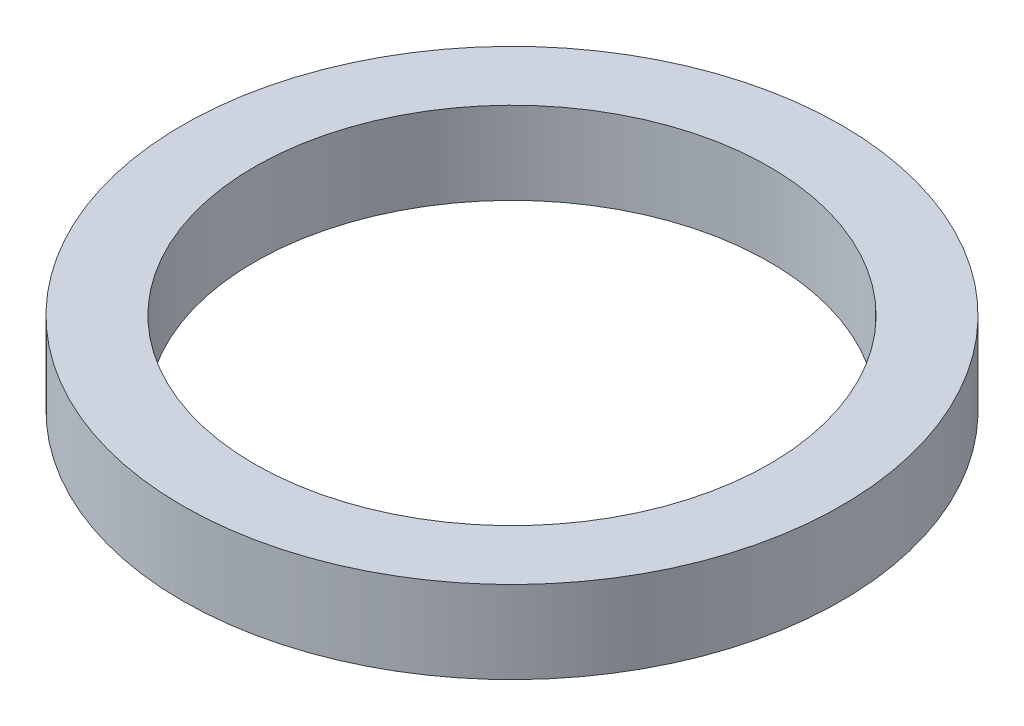
from build123d import *

# Parameters (mm, degrees)
SKETCH1_R           = 16
SKETCH1_R_2         = 12.5
BOSS_EXTRUDE1_DEPTH = 4


with BuildPart() as part:
    # Sketch1 → Boss-Extrude1 (new body)
    with BuildSketch(Plane(origin=(0, 0, 0), x_dir=(1, 0, 0), z_dir=(0, 1, 0))):
        Circle(SKETCH1_R)
        Circle(SKETCH1_R_2, mode=Mode.SUBTRACT)
    extrude(amount=BOSS_EXTRUDE1_DEPTH)


solid = part.part
